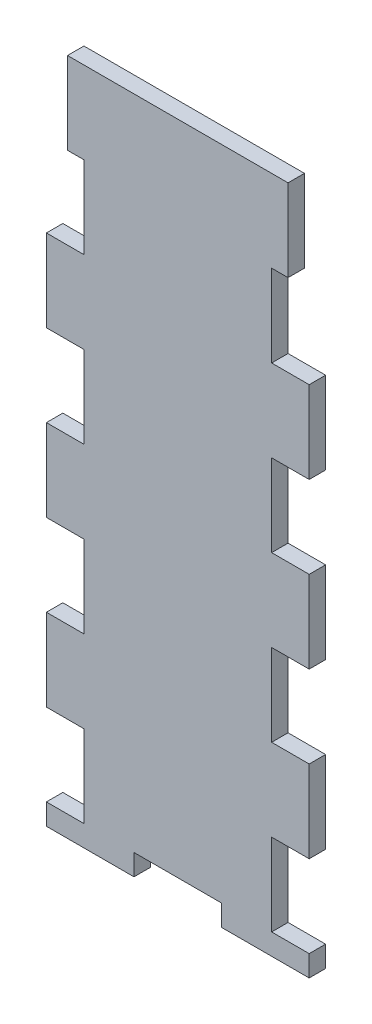
from build123d import *

# Parameters (mm, degrees)
SKETCH1_W           = 20
SKETCH1_H           = 70
SKETCH1_W_2         = 4
SKETCH1_H_2         = 8.75
BOSS_EXTRUDE1_DEPTH = 1.75
SKETCH2_W           = 28
SKETCH2_H           = 2.25
BOSS_EXTRUDE2_DEPTH = 1.75
SKETCH3_W           = 9.333333334
SKETCH3_H           = 2.25
CUT_EXTRUDE1_DEPTH  = 2.75
SKETCH4_W           = 2.25
SKETCH4_H           = 8.75
CUT_EXTRUDE2_DEPTH  = 2.75


with BuildPart() as part:
    # Sketch1 → Boss-Extrude1 (new body)
    with BuildSketch(Plane.XY):
        with Locations((10, 35)):
            Rectangle(SKETCH1_W, SKETCH1_H)
        with Locations((-2, 48.125)):
            Rectangle(SKETCH1_W_2, SKETCH1_H_2)
        with Locations((-2, 13.125)):
            Rectangle(SKETCH1_W_2, SKETCH1_H_2)
        with Locations((-2, 65.625)):
            Rectangle(SKETCH1_W_2, SKETCH1_H_2)
        with Locations((22, 65.625)):
            Rectangle(SKETCH1_W_2, SKETCH1_H_2)
        with Locations((22, 48.125)):
            Rectangle(SKETCH1_W_2, SKETCH1_H_2)
        with Locations((22, 13.125)):
            Rectangle(SKETCH1_W_2, SKETCH1_H_2)
        with Locations((22, 30.625)):
            Rectangle(SKETCH1_W_2, SKETCH1_H_2)
        with Locations((-2, 30.625)):
            Rectangle(SKETCH1_W_2, SKETCH1_H_2)
    extrude(amount=BOSS_EXTRUDE1_DEPTH)

    # Sketch2 → Boss-Extrude2 (add)
    with BuildSketch(Plane(origin=(0, 0, 0), x_dir=(-1, 0, 0), z_dir=(0, 0, -1))):
        with Locations((-10, -1.125)):
            Rectangle(SKETCH2_W, SKETCH2_H)
    extrude(amount=-BOSS_EXTRUDE2_DEPTH)

    # Sketch3 → Cut-Extrude1 (cut, through all)
    with BuildSketch(Plane.XY.offset(1.75)):
        with Locations((10, -1.125)):
            Rectangle(SKETCH3_W, SKETCH3_H)
    extrude(amount=-CUT_EXTRUDE1_DEPTH, mode=Mode.SUBTRACT)

    # Sketch4 → Cut-Extrude2 (cut, through all)
    with BuildSketch(Plane.XY.offset(1.75)):
        with Locations((-2.875, 65.625)):
            Rectangle(SKETCH4_W, SKETCH4_H)
        with Locations((22.875, 65.625)):
            Rectangle(SKETCH4_W, SKETCH4_H)
    extrude(amount=-CUT_EXTRUDE2_DEPTH, mode=Mode.SUBTRACT)


solid = part.part
